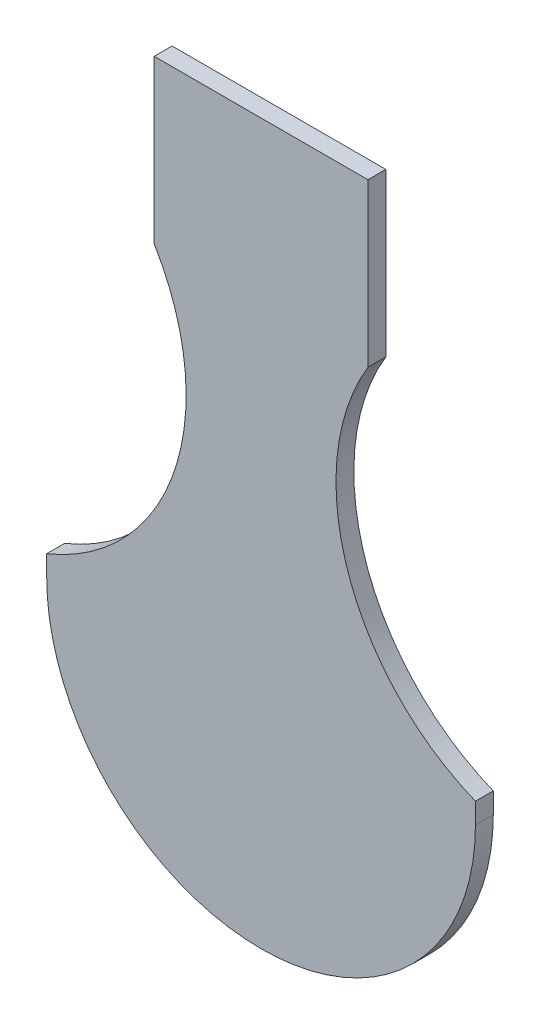
from build123d import *

# Parameters (mm, degrees)
BOSS_EXTRUDE1_DEPTH = 5
CUT_EXTRUDE1_DEPTH  = 6


with BuildPart() as part:
    # Sketch1 → Boss-Extrude1 (new body)
    with BuildSketch(Plane.XY):
        with BuildLine():
            Line((60, 65.777063513), (60, 0))
            Line((60, 0), (-60, 0))
            Line((-60, 0), (-60, 65.777063513))
            ThreePointArc((-60, 65.777063513), (-24.19023261, 103.909288798), (-29.909652169, 155.906349155))
            Line((-29.909652169, 155.906349155), (-29.909646989, 201.396349155))
            Line((-29.909646989, 201.396349155), (29.909657349, 201.396349155))
            Line((29.909657349, 201.396349155), (29.909652169, 155.906349155))
            ThreePointArc((29.909652169, 155.906349155), (24.19023261, 103.909288798), (60, 65.777063513))
        make_face()
    extrude(amount=BOSS_EXTRUDE1_DEPTH)

    # Sketch2 → Cut-Extrude1 (cut, through all)
    with BuildSketch(Plane.XY.offset(5)):
        with BuildLine():
            Line((-60, 60), (-60, -14.155296416))
            Line((-60, -14.155296416), (60, -14.155296416))
            Line((60, -14.155296416), (60, 60))
            ThreePointArc((60, 60), (0, 0), (-60, 60))
        make_face()
    extrude(amount=-CUT_EXTRUDE1_DEPTH, mode=Mode.SUBTRACT)


solid = part.part
